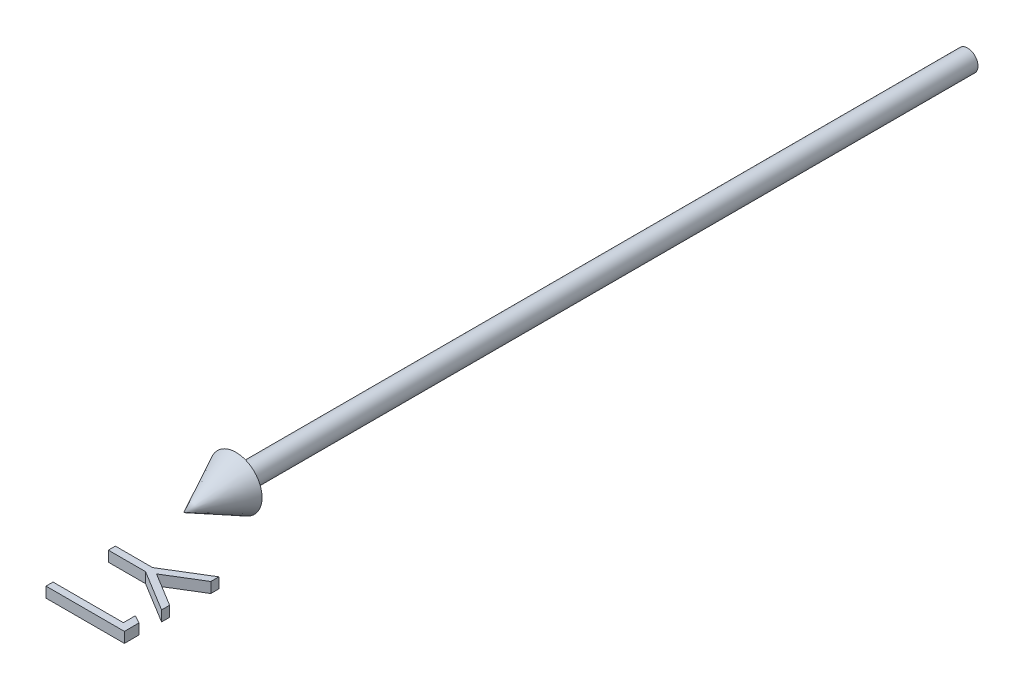
from build123d import *

# Parameters (mm, degrees)
BOSS_EXTRUDE1_DEPTH        = 1
BOSS_EXTRUDE1_DEPTH_BACK   = 1
BOSS_EXTRUDE1_2_DEPTH      = 1
BOSS_EXTRUDE1_2_DEPTH_BACK = 1


with BuildPart() as part:
    # Sketch2 → Revolve1 (revolve)
    with BuildSketch(Plane(origin=(0, 0, 0), x_dir=(1, 0, 0), z_dir=(0, 1, 0))):
        Polygon((0, -150), (5, -140), (2, -140), (2, 0), (0, 0), align=None)
    revolve(axis=Axis((0, 0, -41.949952025), (0, 0, 1)))


with BuildPart() as body_2:
    # Sketch3 → Boss-Extrude1 (new, two sides: drawn at the far end of the back side and taken through both)
    with BuildSketch(Plane(origin=(0, 0, 0), x_dir=(1, 0, 0), z_dir=(0, 1, 0)).offset(-BOSS_EXTRUDE1_DEPTH_BACK)):
        Polygon((15, -158.269230769), (15, -159.810697115), (8.5546875, -163.753004808), (15, -167.689302885), (15, -169.230769231), (7.130408654, -164.423076923), (0, -164.423076923), (0, -163.076923077), (7.130408654, -163.076923077), align=None)
    extrude(amount=BOSS_EXTRUDE1_DEPTH + BOSS_EXTRUDE1_DEPTH_BACK)


with BuildPart() as body_3:
    # Sketch3 → Boss-Extrude1 2 (new, two sides: drawn at the far end of the back side and taken through both)
    with BuildSketch(Plane(origin=(0, 0, 0), x_dir=(1, 0, 0), z_dir=(0, 1, 0)).offset(-BOSS_EXTRUDE1_2_DEPTH_BACK)):
        Polygon((15, -173.572716346), (15, -176.346153846), (0, -176.346153846), (0, -175), (13.461538462, -175), (13.461538462, -172.692307692), align=None)
    extrude(amount=BOSS_EXTRUDE1_2_DEPTH + BOSS_EXTRUDE1_2_DEPTH_BACK)


solid = Compound([part.part, body_2.part, body_3.part])
